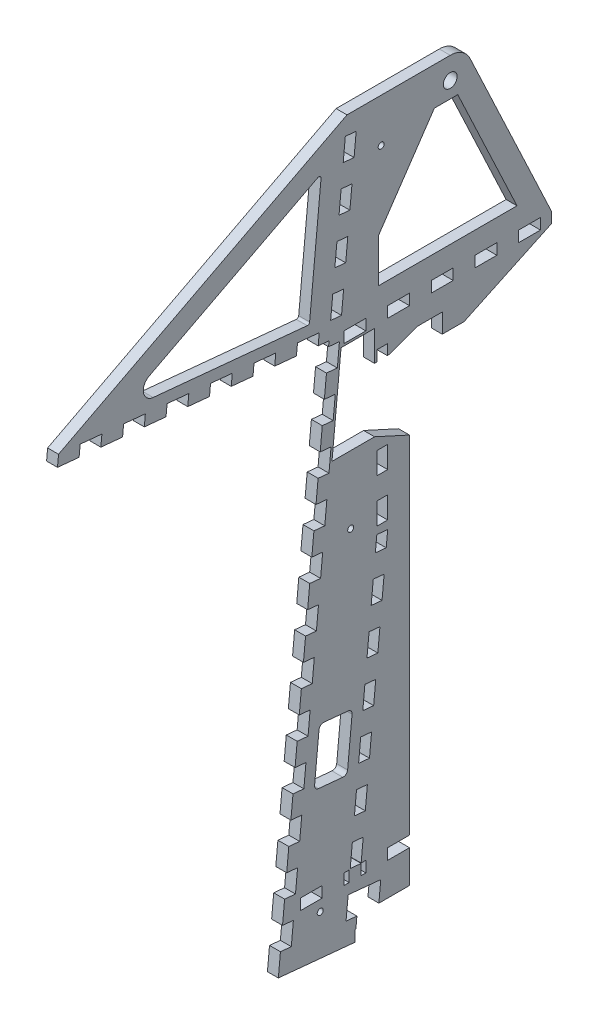
from build123d import *

# Parameters (mm, degrees)
BOSS_EXTRUDE1_DEPTH = 6.35
SKETCH2_W           = 19.05
SKETCH2_H           = 84.666666666
SKETCH2_H_2         = 84.666666667
CUT_EXTRUDE4_DEPTH  = 7.35
FILLET1_R           = 12.7
SKETCH3_R           = 4
CUT_EXTRUDE5_DEPTH  = 7.35
FILLET2_R           = 6.35
CUT_EXTRUDE6_DEPTH  = 7.35
CUT_EXTRUDE11_DEPTH = 7.35
LPATTERN1_COUNT     = 17
LPATTERN1_PITCH     = 25.4
CUT_EXTRUDE13_DEPTH = 7.35
LPATTERN2_COUNT     = 17
LPATTERN2_PITCH     = 25.4
SKETCH8_W           = 12.7
SKETCH8_H           = 6.35
CUT_EXTRUDE14_DEPTH = 7.35
LPATTERN3_COUNT     = 5
LPATTERN3_PITCH     = 25.4
SKETCH9_W           = 12.7
SKETCH9_H           = 6.35
CUT_EXTRUDE15_DEPTH = 7.35
LPATTERN4_COUNT     = 3
LPATTERN4_PITCH     = 25.4
CUT_EXTRUDE16_DEPTH = 7.35
LPATTERN5_COUNT     = 8
LPATTERN5_PITCH     = 25.4
BOSS_EXTRUDE2_DEPTH = 6.35
SKETCH13_W          = 12.7
SKETCH13_H          = 6.35
CUT_EXTRUDE17_DEPTH = 7.35
LPATTERN6_COUNT     = 3
LPATTERN6_PITCH     = 25.4
SKETCH15_W          = 2.976007875
SKETCH15_H          = 6.35
CUT_EXTRUDE20_DEPTH = 7.35
CUT_EXTRUDE21_DEPTH = 7.35
SKETCH17_W          = 6.35
SKETCH17_H          = 6.35
CUT_EXTRUDE22_DEPTH = 7.35
SKETCH18_W          = 6.35
SKETCH18_H          = 12.7
CUT_EXTRUDE23_DEPTH = 7.35
LPATTERN7_COUNT     = 4
LPATTERN7_PITCH     = 25.4
SKETCH19_R          = 1.75
CUT_EXTRUDE24_DEPTH = 7.35
CUT_EXTRUDE25_DEPTH = 7.35
SKETCH25_W          = 6.35
SKETCH25_H          = 6.35
BOSS_EXTRUDE3_DEPTH = 6.35
SKETCH27_W          = 11.164757301
SKETCH27_H          = 7.479550949
CUT_EXTRUDE26_DEPTH = 7.35
FILLET3_R           = 2.54
FILLET4_R           = 1.27
SKETCH28_W          = 35.275818307
SKETCH28_H          = 25.4
CUT_EXTRUDE27_DEPTH = 7.35
CUT_EXTRUDE28_DEPTH = 7.35
SKETCH30_W          = 50.8
SKETCH30_H          = 12.7
CUT_EXTRUDE29_DEPTH = 7.35
SKETCH31_W          = 31.75
SKETCH31_H          = 268.194117647
CUT_EXTRUDE30_DEPTH = 7.35


with BuildPart() as part:
    # Sketch1 → Boss-Extrude1 (new body)
    with BuildSketch(Plane(origin=(0, 0, 0), x_dir=(0, 0, -1), z_dir=(1, 0, 0))):
        Polygon((-128.051747831, 325.716377135), (29.898471713, 310.507500832), (0.41022444, 4.2603437), (44.655585457, 0), (108.458541785, 0), (108.458541785, 280.894117647), (159.258541785, 304.8), (159.258541785, 311.15), (108.458541785, 419.1), (40.3547401, 419.1), (-127.443127302, 332.037142994), align=None)
    extrude(amount=BOSS_EXTRUDE1_DEPTH)

    # Sketch2 → Cut-Extrude4 (cut, through all)
    with BuildSketch(Plane(origin=(6.35, 0, 0), x_dir=(0, 0, -1), z_dir=(1, 0, 0))):
        Polygon((-93.813479632, 335.17834558), (25.474926883, 397.071798933), (18.474181051, 324.366273609), align=None)
        Polygon((91.177408074, 397.071798933), (84.126950747, 323.85), (139.246110214, 323.85), (104.788793069, 397.071798933), align=None)
        Polygon((81.069773467, 292.1), (76.708541785, 246.806877223), (76.708541785, 207.433333333), (95.758541785, 207.433333333), (95.758541785, 292.1), align=None)
        with Locations((86.233541785, 152.4)):
            Rectangle(SKETCH2_W, SKETCH2_H)
        with Locations((86.233541785, 55.033333334)):
            Rectangle(SKETCH2_W, SKETCH2_H_2)
    extrude(amount=-CUT_EXTRUDE4_DEPTH, mode=Mode.SUBTRACT)

    # Fillet1
    fillet1_edges = [part.edges().sort_by_distance(p)[0] for p in [
        (3.175, 419.1, -108.458541785),
    ]]
    fillet(fillet1_edges, radius=FILLET1_R)

    # Sketch3 → Cut-Extrude5 (cut, through all)
    with BuildSketch(Plane(origin=(6.35, 0, 0), x_dir=(0, 0, -1), z_dir=(1, 0, 0))):
        with Locations((100.399051391, 406.4)):
            Circle(SKETCH3_R)
    extrude(amount=-CUT_EXTRUDE5_DEPTH, mode=Mode.SUBTRACT)

    # Fillet2
    fillet2_edges = [part.edges().sort_by_distance(p)[0] for p in [
        (3.175, 335.17834558, 93.813479632),
    ]]
    fillet(fillet2_edges, radius=FILLET2_R)

    # Sketch4 → Cut-Extrude6 (cut, through all)
    with BuildSketch(Plane(origin=(6.35, 0, 0), x_dir=(0, 0, -1), z_dir=(1, 0, 0))):
        Polygon((21.256152575, 88.249017223), (24.323216655, 120.10169557), (43.534363284, 118.251872547), (40.467299203, 86.399194199), align=None)
    extrude(amount=-CUT_EXTRUDE6_DEPTH, mode=Mode.SUBTRACT)

    # Sketch5 → Cut-Extrude11 (cut, through all)
    with BuildSketch(Plane(origin=(6.35, 0, 0), x_dir=(0, 0, -1), z_dir=(1, 0, 0))):
        Polygon((1.627465497, 16.901875419), (2.844706554, 29.543407138), (9.165472413, 28.93478661), (7.948231356, 16.29325489), align=None)
    cut_extrude11 = extrude(amount=-CUT_EXTRUDE11_DEPTH, mode=Mode.SUBTRACT)

    # LPattern1: Cut-Extrude11 ×17
    with Locations(*[Vector(0, 0.995396198, -0.095845753) * (i * LPATTERN1_PITCH) for i in range(1, LPATTERN1_COUNT)]):
        add(cut_extrude11, mode=Mode.SUBTRACT)

    # Sketch7 → Cut-Extrude13 (cut, through all)
    with BuildSketch(Plane(origin=(6.35, 0, 0), x_dir=(0, 0, -1), z_dir=(1, 0, 0))):
        Polygon((23.577705854, 311.116121361), (10.936174134, 312.333362418), (11.544794663, 318.654128277), (24.186326382, 317.43688722), align=None)
    cut_extrude13 = extrude(amount=-CUT_EXTRUDE13_DEPTH, mode=Mode.SUBTRACT)

    # LPattern2: Cut-Extrude13 ×17
    with Locations(*[Vector(0, 0.095845753, 0.995396198) * (i * LPATTERN2_PITCH) for i in range(1, LPATTERN2_COUNT)]):
        add(cut_extrude13, mode=Mode.SUBTRACT)

    # Sketch8 → Cut-Extrude14 (cut, through all)
    with BuildSketch(Plane(origin=(6.35, 0, 0), x_dir=(0, 0, -1), z_dir=(1, 0, 0))):
        with Locations((146.558541785, 307.975)):
            Rectangle(SKETCH8_W, SKETCH8_H)
    cut_extrude14 = extrude(amount=-CUT_EXTRUDE14_DEPTH, mode=Mode.SUBTRACT)

    # LPattern3: Cut-Extrude14 ×5
    with Locations(*[(0, 0, i * LPATTERN3_PITCH) for i in range(1, LPATTERN3_COUNT)]):
        add(cut_extrude14, mode=Mode.SUBTRACT)

    # Sketch9 → Cut-Extrude15 (cut, through all)
    with BuildSketch(Plane(origin=(6.35, 0, 0), x_dir=(0, 0, -1), z_dir=(1, 0, 0))):
        with Locations((102.108541785, 3.175)):
            Rectangle(SKETCH9_W, SKETCH9_H)
    cut_extrude15 = extrude(amount=-CUT_EXTRUDE15_DEPTH, mode=Mode.SUBTRACT)

    # LPattern4: Cut-Extrude15 ×3
    with Locations(*[(0, 0, i * LPATTERN4_PITCH) for i in range(1, LPATTERN4_COUNT)]):
        add(cut_extrude15, mode=Mode.SUBTRACT)

    # Sketch11 → Cut-Extrude16 (cut, through all)
    with BuildSketch(Plane(origin=(6.35, 0, 0), x_dir=(0, 0, -1), z_dir=(1, 0, 0))):
        Polygon((39.800909704, 13.22619081), (46.121675564, 12.617570281), (47.338916621, 25.259102), (41.018150761, 25.867722529), align=None)
    cut_extrude16 = extrude(amount=-CUT_EXTRUDE16_DEPTH, mode=Mode.SUBTRACT)

    # LPattern5: Cut-Extrude16 ×8
    with Locations(*[Vector(0, 0.995396198, -0.095845753) * (i * LPATTERN5_PITCH) for i in range(1, LPATTERN5_COUNT)]):
        add(cut_extrude16, mode=Mode.SUBTRACT)

    # Sketch12 → Boss-Extrude2 (add, through all)
    with BuildSketch(Plane(origin=(6.35, 0, 0), x_dir=(0, 0, -1), z_dir=(1, 0, 0))):
        Polygon((58.059525559, 202.849166599), (64.380291419, 202.24054607), (64.008541785, 198.379778502), (57.687775925, 198.988399031), align=None)
    extrude(amount=-BOSS_EXTRUDE2_DEPTH)

    # Sketch13 → Cut-Extrude17 (cut, through all)
    with BuildSketch(Plane(origin=(6.35, 0, 0), x_dir=(0, 0, -1), z_dir=(1, 0, 0))):
        with Locations((70.358541785, 34.925)):
            Rectangle(SKETCH13_W, SKETCH13_H)
    cut_extrude17 = extrude(amount=-CUT_EXTRUDE17_DEPTH, mode=Mode.SUBTRACT)

    # LPattern6: Cut-Extrude17 ×3, 1 skipped
    with Locations(*[(0, 0, i * LPATTERN6_PITCH) for i in range(1, LPATTERN6_COUNT) if i not in (1,)]):
        add(cut_extrude17, mode=Mode.SUBTRACT)

    # Sketch15 → Cut-Extrude20 (cut, through all)
    with BuildSketch(Plane(origin=(6.35, 0, 0), x_dir=(0, 0, -1), z_dir=(1, 0, 0))):
        with Locations((40.096545722, 34.925)):
            Rectangle(SKETCH15_W, SKETCH15_H)
        Polygon((48.575354467, 31.75), (51.308541785, 31.75), (51.308541785, 38.1), (48.575354467, 38.1), (48.556157678, 37.90063372), (48.575354467, 37.90063372), align=None)
    extrude(amount=-CUT_EXTRUDE20_DEPTH, mode=Mode.SUBTRACT)

    # Sketch16 → Cut-Extrude21 (cut, through all)
    with BuildSketch(Plane(origin=(6.35, 0, 0), x_dir=(0, 0, -1), z_dir=(1, 0, 0))):
        Polygon((47.338916621, 25.259102), (45.518177187, 6.35), (58.276915889, 6.35), (59.98044834, 24.041860943), align=None)
    extrude(amount=-CUT_EXTRUDE21_DEPTH, mode=Mode.SUBTRACT)

    # Sketch17 → Cut-Extrude22 (cut, through all)
    with BuildSketch(Plane(origin=(6.35, 0, 0), x_dir=(0, 0, -1), z_dir=(1, 0, 0))):
        with Locations((60.833541785, 307.975)):
            Rectangle(SKETCH17_W, SKETCH17_H)
    extrude(amount=-CUT_EXTRUDE22_DEPTH, mode=Mode.SUBTRACT)

    # Sketch18 → Cut-Extrude23 (cut, through all)
    with BuildSketch(Plane(origin=(6.35, 0, 0), x_dir=(0, 0, -1), z_dir=(1, 0, 0))):
        with Locations((60.833541785, 285.75)):
            Rectangle(SKETCH18_W, SKETCH18_H)
    cut_extrude23 = extrude(amount=-CUT_EXTRUDE23_DEPTH, mode=Mode.SUBTRACT)

    # LPattern7: Cut-Extrude23 ×4
    with Locations(*[(0, -i * LPATTERN7_PITCH, 0) for i in range(1, LPATTERN7_COUNT)]):
        add(cut_extrude23, mode=Mode.SUBTRACT)

    # Sketch19 → Cut-Extrude24 (cut, through all)
    with BuildSketch(Plane(origin=(6.35, 0, 0), x_dir=(0, 0, -1), z_dir=(1, 0, 0))):
        with Locations((42.505326788, 209.551703302)):
            Circle(SKETCH19_R)
        with Locations((60.236791004, 393.7)):
            Circle(SKETCH19_R)
        with Locations((24.773862572, 25.403406604)):
            Circle(SKETCH19_R)
    extrude(amount=-CUT_EXTRUDE24_DEPTH, mode=Mode.SUBTRACT)

    # Sketch20 → Cut-Extrude25 (cut, through all)
    with BuildSketch(Plane.ZY):
        Polygon((-56.388541785, 248.92), (-31.623513099, 248.92), (-36.881858021, 303.53), (-56.388541785, 303.53), (-56.388541785, 283.116766323), (-81.069773467, 292.1), (-76.708541785, 239.638910332), align=None)
    extrude(amount=-CUT_EXTRUDE25_DEPTH, mode=Mode.SUBTRACT)

    # Sketch25 → Boss-Extrude3 (add, through all)
    with BuildSketch(Plane.ZY):
        with Locations((-60.833541785, 307.975)):
            Rectangle(SKETCH25_W, SKETCH25_H)
    extrude(amount=-BOSS_EXTRUDE3_DEPTH)

    # Sketch27 → Cut-Extrude26 (cut, through all)
    with BuildSketch(Plane.ZY):
        with Locations((-58.426163135, 282.150444034)):
            Rectangle(SKETCH27_W, SKETCH27_H)
    extrude(amount=-CUT_EXTRUDE26_DEPTH, mode=Mode.SUBTRACT)

    # Fillet3
    fillet3_edges = [part.edges().sort_by_distance(p)[0] for p in [
        (3.175, 86.399194199, -40.467299203),
        (3.175, 88.249017223, -21.256152575),
        (3.175, 120.10169557, -24.323216655),
        (3.175, 118.251872547, -43.534363284),
    ]]
    fillet(fillet3_edges, radius=FILLET3_R)

    # Fillet4
    fillet4_edges = [part.edges().sort_by_distance(p)[0] for p in [
        (3.175, 324.366273609, -18.474181051),
        (3.175, 397.071798933, -25.474926883),
    ]]
    fillet(fillet4_edges, radius=FILLET4_R)

    # Sketch28 → Cut-Extrude27 (cut, through all)
    with BuildSketch(Plane.ZY):
        with Locations((-76.364859901, 336.55)):
            Rectangle(SKETCH28_W, SKETCH28_H)
    extrude(amount=-CUT_EXTRUDE27_DEPTH, mode=Mode.SUBTRACT)

    # Sketch29 → Cut-Extrude28 (cut, through all)
    with BuildSketch(Plane.ZY):
        Polygon((-91.177408074, 397.071798933), (-58.726950747, 349.25), (-86.572692571, 349.25), align=None)
    extrude(amount=-CUT_EXTRUDE28_DEPTH, mode=Mode.SUBTRACT)

    # Sketch30 → Cut-Extrude29 (cut, through all)
    with BuildSketch(Plane.ZY):
        with Locations((-83.058541785, 6.35)):
            Rectangle(SKETCH30_W, SKETCH30_H)
    extrude(amount=-CUT_EXTRUDE29_DEPTH, mode=Mode.SUBTRACT)

    # Sketch31 → Cut-Extrude30 (cut, through all)
    with BuildSketch(Plane.ZY):
        with Locations((-92.583541785, 146.797058824)):
            Rectangle(SKETCH31_W, SKETCH31_H)
    extrude(amount=-CUT_EXTRUDE30_DEPTH, mode=Mode.SUBTRACT)


solid = part.part
